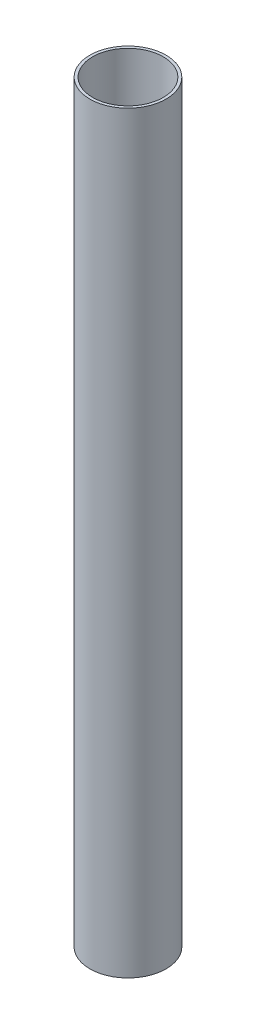
from build123d import *

# Parameters (mm, degrees)
SKETCH1_R           = 41.099994
SKETCH1_R_2         = 38.1
BOSS_EXTRUDE1_DEPTH = 812.8


with BuildPart() as part:
    # Sketch1 → Boss-Extrude1 (new body)
    with BuildSketch(Plane(origin=(0, 0, 0), x_dir=(1, 0, 0), z_dir=(0, 1, 0))):
        Circle(SKETCH1_R)
        Circle(SKETCH1_R_2, mode=Mode.SUBTRACT)
    extrude(amount=BOSS_EXTRUDE1_DEPTH)


solid = part.part
